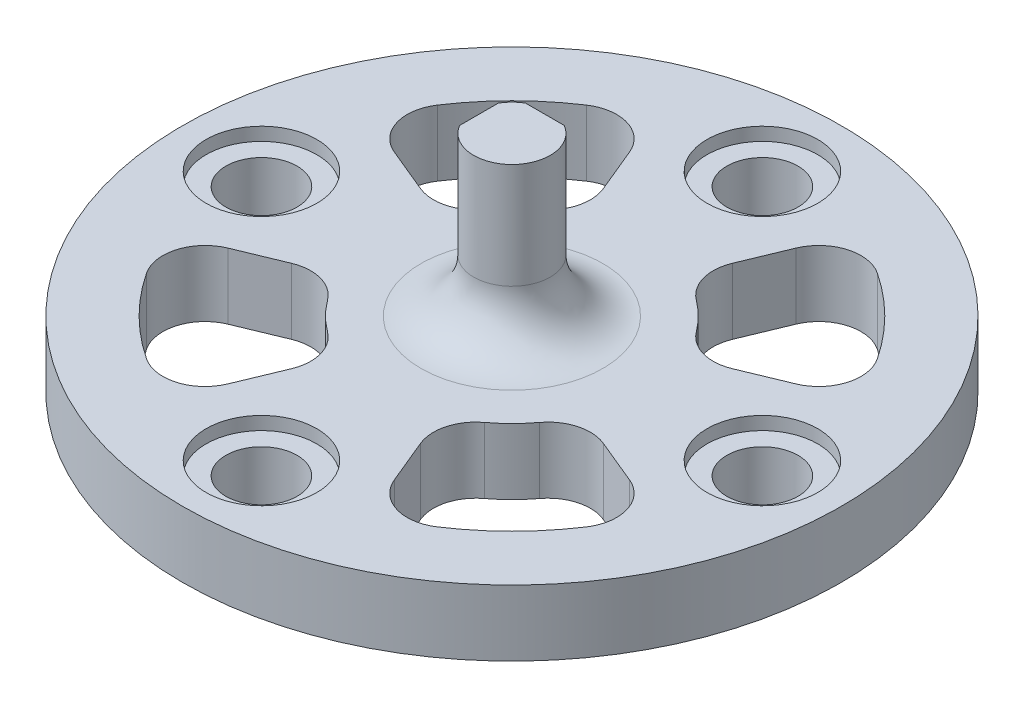
from build123d import *

# Parameters (mm, degrees)
SKETCH1_R                = 12.5
BOSS_EXTRUDE1_DEPTH      = 2.5
SKETCH2_R                = 1.35
CUT_EXTRUDE1_DEPTH       = 3.5
SKETCH4_R                = 2.1
CUT_EXTRUDE2_DEPTH       = 0.5
CUT_EXTRUDE3_DEPTH       = 3.5
FILLET3_R                = 1.6
CIRPATTERN1_COUNT        = 4
FILLET3_OF_CIRPATTERN1_R = 1.6
SKETCH3_R                = 1.45
BOSS_EXTRUDE2_DEPTH      = 6
FILLET2_R                = 2
SKETCH6_W                = 1.469693846
SKETCH6_H                = 0.4
SKETCH6_W_2              = 0.4
SKETCH6_H_2              = 1.469693846
CUT_EXTRUDE4_DEPTH       = 4


with BuildPart() as part:
    # Sketch1 → Boss-Extrude1 (new body)
    with BuildSketch(Plane(origin=(0, 0, 0), x_dir=(1, 0, 0), z_dir=(0, 1, 0))):
        Circle(SKETCH1_R)
    extrude(amount=BOSS_EXTRUDE1_DEPTH)

    # Sketch2 → Cut-Extrude1 (cut, through all)
    with BuildSketch(Plane(origin=(0, 2.5, 0), x_dir=(1, 0, 0), z_dir=(0, 1, 0))):
        with Locations((0, 9.5)):
            Circle(SKETCH2_R)
    cut_extrude1 = extrude(amount=-CUT_EXTRUDE1_DEPTH, mode=Mode.SUBTRACT)

    # Sketch4 → Cut-Extrude2 (cut)
    with BuildSketch(Plane(origin=(0, 2.5, 0), x_dir=(1, 0, 0), z_dir=(0, 1, 0))):
        with Locations((0, 9.5)):
            Circle(SKETCH4_R)
    cut_extrude2 = extrude(amount=-CUT_EXTRUDE2_DEPTH, mode=Mode.SUBTRACT)

    # Sketch5 → Cut-Extrude3 (cut, through all)
    with BuildSketch(Plane(origin=(0, 2.5, 0), x_dir=(1, 0, 0), z_dir=(0, 1, 0))):
        with BuildLine():
            Line((1.913417162, 4.619397663), (3.826834324, 9.238795325))
            ThreePointArc((3.826834324, 9.238795325), (7.071067812, 7.071067812), (9.238795325, 3.826834324))
            Line((9.238795325, 3.826834324), (4.619397663, 1.913417162))
            ThreePointArc((4.619397663, 1.913417162), (3.535533906, 3.535533906), (1.913417162, 4.619397663))
        make_face()
    cut_extrude3 = extrude(amount=-CUT_EXTRUDE3_DEPTH, mode=Mode.SUBTRACT)

    # Fillet3
    fillet3_edges = [part.edges().sort_by_distance(p)[0] for p in [
        (3.826834324, 1.25, -9.238795325),
        (9.238795325, 1.25, -3.826834324),
        (4.619397663, 1.25, -1.913417162),
        (1.913417162, 1.25, -4.619397663),
    ]]
    fillet(fillet3_edges, radius=FILLET3_R)

    # CirPattern1: Cut-Extrude1, Cut-Extrude2, Cut-Extrude3 ×4 about axis
    cirpattern1_axis = Axis((0, 0, 0), (0, 1, 0))
    for i in range(1, CIRPATTERN1_COUNT):
        add(cut_extrude1.rotate(cirpattern1_axis, i * 360 / CIRPATTERN1_COUNT), mode=Mode.SUBTRACT)
        add(cut_extrude2.rotate(cirpattern1_axis, i * 360 / CIRPATTERN1_COUNT), mode=Mode.SUBTRACT)
        add(cut_extrude3.rotate(cirpattern1_axis, i * 360 / CIRPATTERN1_COUNT), mode=Mode.SUBTRACT)

    # Fillet3 of CirPattern1
    fillet3_of_cirpattern1_edges = [part.edges().sort_by_distance(p)[0] for p in [
        (-9.238795325, 1.25, -3.826834324),
        (-3.826834324, 1.25, -9.238795325),
        (-1.913417162, 1.25, -4.619397663),
        (-4.619397663, 1.25, -1.913417162),
        (-3.826834324, 1.25, 9.238795325),
        (-9.238795325, 1.25, 3.826834324),
        (-4.619397663, 1.25, 1.913417162),
        (-1.913417162, 1.25, 4.619397663),
        (9.238795325, 1.25, 3.826834324),
        (3.826834324, 1.25, 9.238795325),
        (1.913417162, 1.25, 4.619397663),
        (4.619397663, 1.25, 1.913417162),
    ]]
    fillet(fillet3_of_cirpattern1_edges, radius=FILLET3_OF_CIRPATTERN1_R)

    # Sketch3 → Boss-Extrude2 (add)
    with BuildSketch(Plane(origin=(0, 2.5, 0), x_dir=(1, 0, 0), z_dir=(0, 1, 0))):
        Circle(SKETCH3_R)
    extrude(amount=BOSS_EXTRUDE2_DEPTH)

    # Fillet2
    fillet2_edges = [part.edges().sort_by_distance(p)[0] for p in [
        (-1.45, 2.5, 0),
    ]]
    fillet(fillet2_edges, radius=FILLET2_R)

    # Sketch6 → Cut-Extrude4 (cut)
    with BuildSketch(Plane(origin=(0, 8.5, 0), x_dir=(1, 0, 0), z_dir=(0, 1, 0))):
        with Locations((0, 1.45)):
            Rectangle(SKETCH6_W, SKETCH6_H)
        with Locations((-1.45, 0)):
            Rectangle(SKETCH6_W_2, SKETCH6_H_2)
    extrude(amount=-CUT_EXTRUDE4_DEPTH, mode=Mode.SUBTRACT)


solid = part.part
